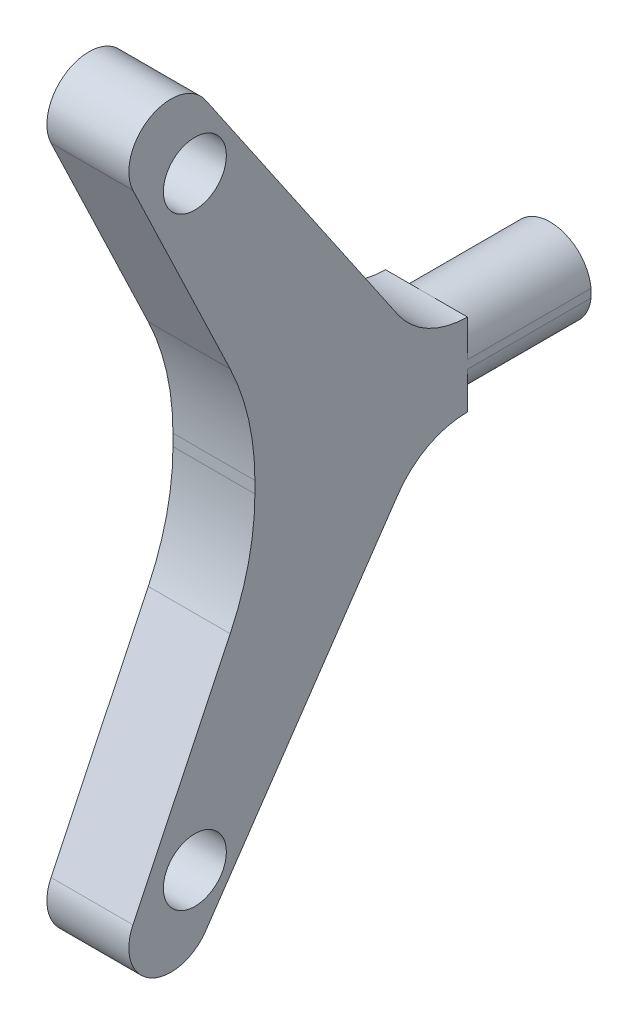
from build123d import *

# Parameters (mm, degrees)
BOSS_EXTRUDE1_DEPTH = 4.875
SKETCH3_OUTSIDE_W   = 32.934
SKETCH3_OUTSIDE_H   = 113.184
SKETCH3_OUTSIDE_R   = 4.9
CUT_EXTRUDE1_DEPTH  = 14.716884
SKETCH4_R           = 3.75
CUT_EXTRUDE2_DEPTH  = 9.75


with BuildPart() as part:
    # Sketch2 → Boss-Extrude1 (new body, symmetric)
    with BuildSketch(Plane(origin=(0, 0, 0), x_dir=(0, 0, -1), z_dir=(1, 0, 0))):
        with BuildLine():
            Line((0, -0.695639294), (0, 0.695639294))
            ThreePointArc((0, 0.695639294), (-0.743104239, 7.331455024), (-2.93560336, 13.638530568))
            Line((-2.93560336, 13.638530568), (-14.510732773, 37.842851454))
            ThreePointArc((-14.510732773, 37.842851454), (-12.494794947, 44.333127989), (-5.869704015, 42.817916797))
            Line((-5.869704015, 42.817916797), (17.022523842, 9.264166407))
            ThreePointArc((17.022523842, 9.264166407), (20.611838468, 6.058101563), (25.283115813, 4.9))
            Line((25.283115813, 4.9), (40, 4.9))
            Line((40, 4.9), (40, -4.9))
            Line((40, -4.9), (25.283115813, -4.9))
            ThreePointArc((25.283115813, -4.9), (20.611838468, -6.058101563), (17.022523842, -9.264166407))
            Line((17.022523842, -9.264166407), (-5.869704015, -42.817916797))
            ThreePointArc((-5.869704015, -42.817916797), (-12.494794947, -44.333127989), (-14.510732773, -37.842851454))
            Line((-14.510732773, -37.842851454), (-2.93560336, -13.638530568))
            ThreePointArc((-2.93560336, -13.638530568), (-0.743104239, -7.331455024), (0, -0.695639294))
        make_face()
    extrude(amount=BOSS_EXTRUDE1_DEPTH, both=True)

    # Sketch3 outside → Cut-Extrude1 (cut)
    with BuildSketch(Plane(origin=(0, 0, -40), x_dir=(-1, 0, 0), z_dir=(0, 0, -1))):
        Rectangle(SKETCH3_OUTSIDE_W, SKETCH3_OUTSIDE_H)
        Circle(SKETCH3_OUTSIDE_R, mode=Mode.SUBTRACT)
    extrude(amount=-CUT_EXTRUDE1_DEPTH, mode=Mode.SUBTRACT)

    # Sketch4 → Cut-Extrude2 (cut)
    with BuildSketch(Plane(origin=(4.875, 0, 0), x_dir=(0, 0, -1), z_dir=(1, 0, 0))):
        with Locations((-7.144836337, 35.884581199)):
            Circle(SKETCH4_R)
        with Locations((-7.144836337, -35.884581199)):
            Circle(SKETCH4_R)
    extrude(amount=-CUT_EXTRUDE2_DEPTH, mode=Mode.SUBTRACT)


solid = part.part
